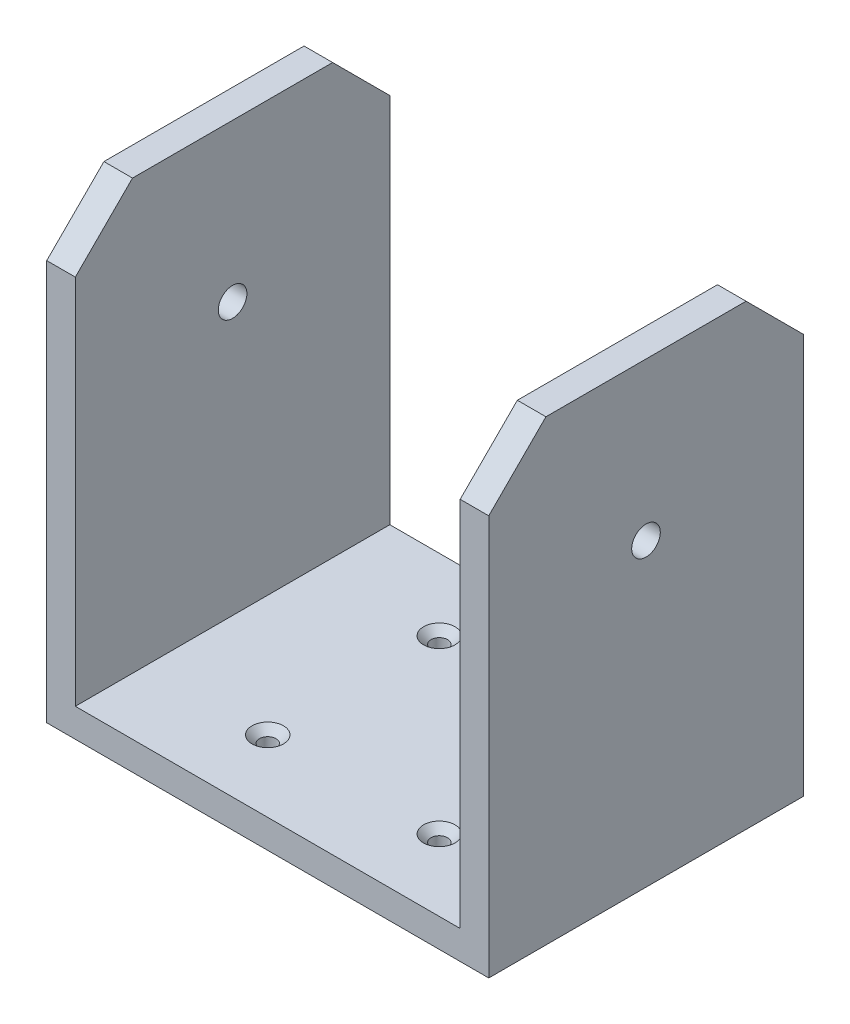
from build123d import *

# Parameters (mm, degrees)
SKETCH1_R                                         = 2.5
BOSS_EXTRUDE1_DEPTH                               = 5
SKETCH2_W                                         = 5
SKETCH2_H                                         = 55
BOSS_EXTRUDE2_DEPTH                               = 25
SKETCH3_W                                         = 72.3
SKETCH3_H                                         = 55
BOSS_EXTRUDE3_DEPTH                               = 5
BOSS_EXTRUDE4_DEPTH                               = 5
CUT_EXTRUDE1_REACH                                = 7
SKETCH5_R                                         = 2.5
CSK_FOR_M2_5_FLAT_HEAD_MACHINE_SCREW1_D           = 2.9
CSK_FOR_M2_5_FLAT_HEAD_MACHINE_SCREW1_CSINK_D     = 5.5
CSK_FOR_M2_5_FLAT_HEAD_MACHINE_SCREW1_CSINK_ANGLE = 90


with BuildPart() as part:
    # Sketch1 → Boss-Extrude1 (new body)
    with BuildSketch(Plane(origin=(0, 0, 0), x_dir=(0, 0, -1), z_dir=(1, 0, 0))):
        Polygon((-27.5, 17.5), (-17.5, 27.5), (17.5, 27.5), (27.5, 17.5), (27.5, -27.5), (-27.5, -27.5), align=None)
        Circle(SKETCH1_R, mode=Mode.SUBTRACT)
    extrude(amount=BOSS_EXTRUDE1_DEPTH)

    # Sketch2 → Boss-Extrude2 (add)
    with BuildSketch(Plane.XZ.offset(27.5)):
        with Locations((2.5, 0)):
            Rectangle(SKETCH2_W, SKETCH2_H)
    extrude(amount=BOSS_EXTRUDE2_DEPTH)

    # Sketch3 → Boss-Extrude3 (add)
    with BuildSketch(Plane.XZ.offset(52.5)):
        with Locations((-36.15, 0)):
            Rectangle(SKETCH3_W, SKETCH3_H)
    extrude(amount=-BOSS_EXTRUDE3_DEPTH)

    # Sketch4 → Boss-Extrude4 (add)
    with BuildSketch(Plane.ZY.offset(72.3)):
        Polygon((-17.5, 27.5), (-27.5, 17.5), (-27.5, -47.5), (27.5, -47.5), (27.5, 17.5), (17.5, 27.5), align=None)
    extrude(amount=-BOSS_EXTRUDE4_DEPTH)

    # Sketch5 → Cut-Extrude1 (cut, up to next)
    with BuildSketch(Plane(origin=(-67.3, 0, 0), x_dir=(0, 0, -1), z_dir=(1, 0, 0)), mode=Mode.PRIVATE) as cut_extrude1_sk1:
        Circle(SKETCH5_R)
    cut_extrude1_tool1 = extrude(cut_extrude1_sk1.sketch, amount=-CUT_EXTRUDE1_REACH, mode=Mode.PRIVATE) & part.part
    add(cut_extrude1_tool1.solids().sort_by_distance((-67.3, 0, 0))[0], mode=Mode.SUBTRACT)

    # CSK for M2.5 Flat Head Machine Screw1 (through all)
    with Locations(Plane(origin=(0, -47.5, 0), x_dir=(1, 0, 0), z_dir=(0, 1, 0))):
        with Locations((-16.15, 15), (-16.15, -15), (-46.15, -15), (-46.15, 15)):
            CounterSinkHole(CSK_FOR_M2_5_FLAT_HEAD_MACHINE_SCREW1_D / 2, CSK_FOR_M2_5_FLAT_HEAD_MACHINE_SCREW1_CSINK_D / 2, counter_sink_angle=CSK_FOR_M2_5_FLAT_HEAD_MACHINE_SCREW1_CSINK_ANGLE)


solid = part.part
